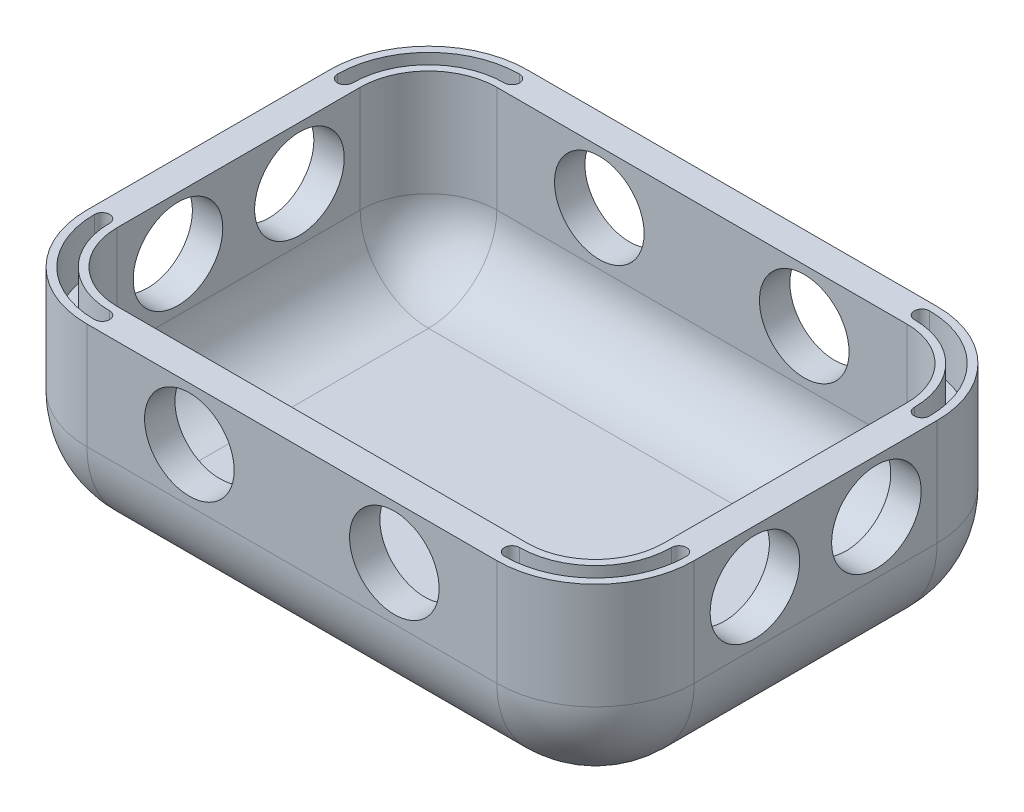
from build123d import *

# Parameters (mm, degrees)
SKETCH1_W               = 40
SKETCH1_H               = 29
BOSS_EXTRUDE1_DEPTH     = 20
FILLET2_R               = 6.5
SKETCH6_W               = 47.866272002
SKETCH6_H               = 35.823148672
CUT_EXTRUDE6_DEPTH      = 7.5
SHELL1_T                = -2
SKETCH7_R               = 2.95
CUT_EXTRUDE7_DEPTH      = 1
CUT_EXTRUDE7_DEPTH_BACK = 41
SKETCH8_R               = 2.95
CUT_EXTRUDE8_DEPTH      = 30
CUT_EXTRUDE10_DEPTH     = 3.3


with BuildPart() as part:
    # Sketch1 → Boss-Extrude1 (new body)
    with BuildSketch(Plane(origin=(0, 0, 0), x_dir=(1, 0, 0), z_dir=(0, 1, 0))):
        Rectangle(SKETCH1_W, SKETCH1_H)
    extrude(amount=BOSS_EXTRUDE1_DEPTH)

    # Fillet2
    fillet2_edges = [part.edges().sort_by_distance(p)[0] for p in [
        (-20, 20, 0),
        (0, 20, 14.5),
        (20, 20, 0),
        (0, 0, 14.5),
        (-20, 0, 0),
        (0, 0, -14.5),
        (20, 0, 0),
        (20, 10, 14.5),
        (-20, 10, 14.5),
        (-20, 10, -14.5),
        (20, 10, -14.5),
        (0, 20, -14.5),
    ]]
    fillet(fillet2_edges, radius=FILLET2_R)

    # Sketch6 → Cut-Extrude6 (cut, through all)
    with BuildSketch(Plane(origin=(0, 13.5, 0), x_dir=(1, 0, 0), z_dir=(0, 1, 0))):
        Rectangle(SKETCH6_W, SKETCH6_H)
    extrude(amount=CUT_EXTRUDE6_DEPTH, mode=Mode.SUBTRACT)

    # Shell1
    shell1_openings = [part.faces().sort_by_distance(p)[0] for p in [
        (0, 13.5, 0),
    ]]
    offset(amount=SHELL1_T, openings=shell1_openings, kind=Kind.INTERSECTION)

    # Sketch7 → Cut-Extrude7 (cut, two sides)
    with BuildSketch(Plane(origin=(20, 0, 0), x_dir=(0, 0, -1), z_dir=(1, 0, 0))) as cut_extrude7_sk:
        with Locations((4, 10)):
            Circle(SKETCH7_R)
        with Locations((-4, 10)):
            Circle(SKETCH7_R)
    extrude(amount=CUT_EXTRUDE7_DEPTH, mode=Mode.SUBTRACT)
    extrude(cut_extrude7_sk.sketch, amount=-CUT_EXTRUDE7_DEPTH_BACK, mode=Mode.SUBTRACT)

    # Sketch8 → Cut-Extrude8 (cut, through all)
    with BuildSketch(Plane.XY.offset(14.5)):
        with Locations((-6.75, 10)):
            Circle(SKETCH8_R)
        with Locations(Location((6.75, 10, 0), (0, 0, 180))):  # turned: the seam where the file's is
            Circle(SKETCH8_R)
    extrude(amount=-CUT_EXTRUDE8_DEPTH, mode=Mode.SUBTRACT)

    # Sketch10 → Cut-Extrude10 (cut)
    with BuildSketch(Plane(origin=(0, 13.5, 0), x_dir=(1, 0, 0), z_dir=(0, 1, 0))):
        with BuildLine():
            ThreePointArc((-18.5, -8), (-17.035533906, -11.535533906), (-13.5, -13))
            ThreePointArc((-13.5, -13), (-13, -13.5), (-13.5, -14))
            ThreePointArc((-13.5, -14), (-17.742640687, -12.242640687), (-19.5, -8))
            ThreePointArc((-19.5, -8), (-19, -7.5), (-18.5, -8))
        make_face()
        with BuildLine():
            ThreePointArc((-13.5, 13), (-17.035533906, 11.535533906), (-18.5, 8))
            ThreePointArc((-18.5, 8), (-19, 7.5), (-19.5, 8))
            ThreePointArc((-19.5, 8), (-17.742640687, 12.242640687), (-13.5, 14))
            ThreePointArc((-13.5, 14), (-13, 13.5), (-13.5, 13))
        make_face()
        with BuildLine():
            ThreePointArc((18.5, 8), (17.035533906, 11.535533906), (13.5, 13))
            ThreePointArc((13.5, 13), (13, 13.5), (13.5, 14))
            ThreePointArc((13.5, 14), (17.742640687, 12.242640687), (19.5, 8))
            ThreePointArc((19.5, 8), (19, 7.5), (18.5, 8))
        make_face()
        with BuildLine():
            ThreePointArc((13.5, -13), (17.035533906, -11.535533906), (18.5, -8))
            ThreePointArc((18.5, -8), (19, -7.5), (19.5, -8))
            ThreePointArc((19.5, -8), (17.742640687, -12.242640687), (13.5, -14))
            ThreePointArc((13.5, -14), (13, -13.5), (13.5, -13))
        make_face()
    extrude(amount=-CUT_EXTRUDE10_DEPTH, mode=Mode.SUBTRACT)


solid = part.part
